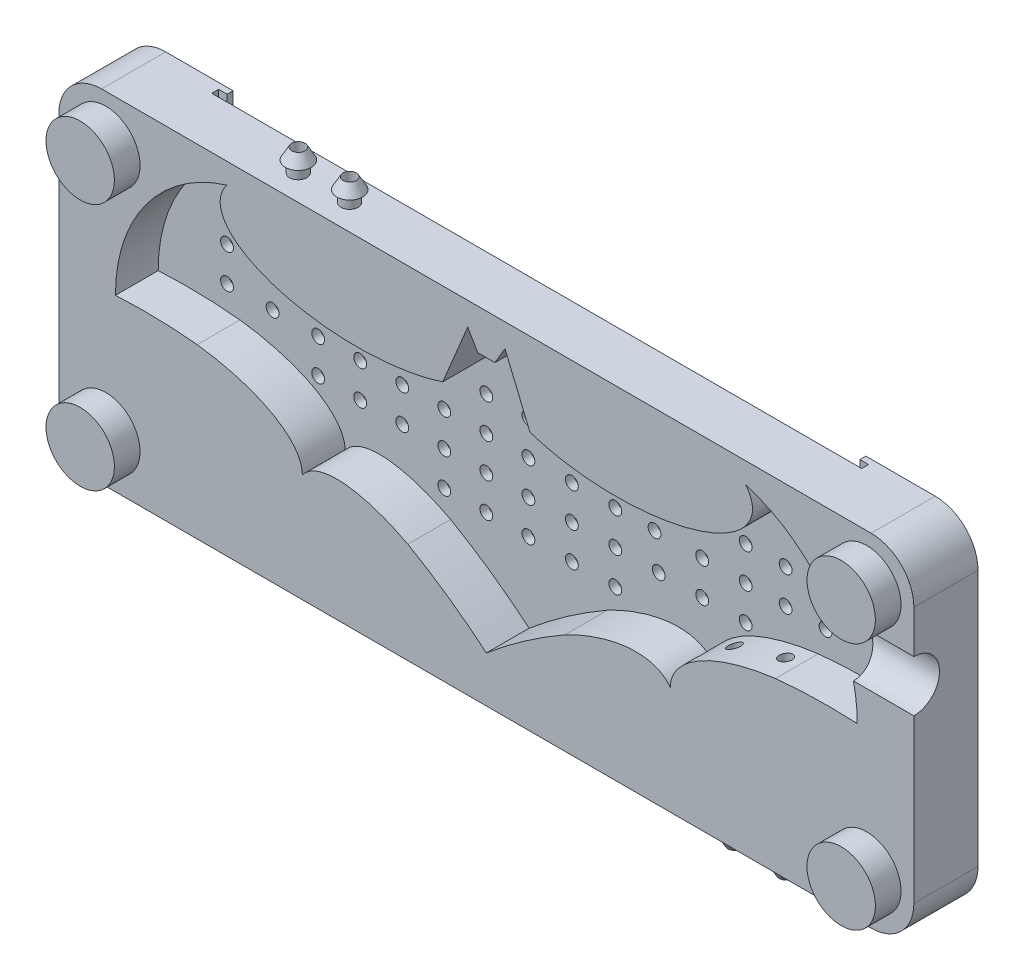
from build123d import *

# Parameters (mm, degrees)
CROQUIS2_W               = 50
CROQUIS2_H               = 40
SALIENTE_EXTRUIR1_DEPTH  = 7.5
CORTAR_EXTRUIR1_DEPTH    = 5
CROQUIS4_R               = 4
SALIENTE_EXTRUIR2_DEPTH  = 3
REDONDEO1_R              = 5
CORTAR_EXTRUIR3_DEPTH    = 10
CROQUIS9_R               = 0.75
CORTAR_EXTRUIR4_DEPTH    = 2.5
CORTAR_EXTRUIR5_DEPTH    = 30
CORTAR_EXTRUIR6_REACH    = 87.646
CROQUIS14_R              = 0.75
CORTAR_EXTRUIR7_REACH    = 87.646
CROQUIS15_R              = 0.75
CROQUIS16_R              = 1
CROQUIS16_R_2            = 0.75
SALIENTE_EXTRUIR6_DEPTH  = 1.3
MATRIZL1_COUNT           = 2
MATRIZL1_PITCH           = 6
CROQUIS27_R              = 1
CROQUIS27_R_2            = 0.75
SALIENTE_EXTRUIR11_DEPTH = 1.3
MATRIZL2_COUNT           = 2
MATRIZL2_PITCH           = 6


with BuildPart() as part:
    # Croquis2 → Saliente-Extruir1 (new body)
    with BuildSketch(Plane.XY):
        Rectangle(CROQUIS2_W, CROQUIS2_H)
    saliente_extruir1 = extrude(amount=SALIENTE_EXTRUIR1_DEPTH)

    # Croquis3 → Cortar-Extruir1 (cut)
    with BuildSketch(Plane.XY.offset(7.5)):
        with BuildLine():
            Line((19.901237938, 10.279897032), (22.822017531, 17.279897032))
            Line((22.822017531, 17.279897032), (24, 15.279897032))
            Line((24, 15.279897032), (25, 15.279897032))
            Line((25, 15.279897032), (25, -14.629122871))
            ThreePointArc((25, -14.629122871), (20.554365751, -11.20741121), (15.817639155, -8.201550981))
            add(Edge.make_bspline(
                [(15.817639155, -8.201550981), (6.428363836, -3.289480245), (3.480591711, -7.371484759)],
                knots=[5.017938201, 5.017938201, 5.017938201, 6.283185307, 6.283185307, 6.283185307], degree=2, weights=[1, 0.806479077, 1]))
            add(Edge.make_bspline(
                [(3.480591711, -7.371484759), (3.499026777, -1.865901054), (-8.816349071, -0.309137944)],
                knots=[3.141592654, 3.141592654, 3.141592654, 4.433520913, 4.433520913, 4.433520913], degree=2, weights=[1, 0.798519762, 1]))
            ThreePointArc((-8.816349071, -0.309137944), (-13.59205679, -0.015988385), (-18.376149655, -0.091990716))
            ThreePointArc((-18.376149655, -0.091990716), (-14.787337114, 10.909903735), (-5.334178799, 17.585160647))
            add(Edge.make_bspline(
                [(-5.334178799, 17.585160647), (-22.119144034, -3.87776365), (19.901237938, 10.279897032)],
                knots=[5.966710887, 5.966710887, 5.966710887, 8.531517406, 8.531517406, 8.531517406], degree=2, weights=[1, 0.284412024, 1]))
        make_face()
    cortar_extruir1 = extrude(amount=-CORTAR_EXTRUIR1_DEPTH, mode=Mode.SUBTRACT)

    # Simetría1: Saliente-Extruir1, Cortar-Extruir1 across plane
    add(saliente_extruir1.mirror(Plane(origin=(25, 20, 7.5), x_dir=(0, 0, 1), z_dir=(-1, 0, 0))))
    add(cortar_extruir1.mirror(Plane(origin=(25, 20, 7.5), x_dir=(0, 0, 1), z_dir=(-1, 0, 0))), mode=Mode.SUBTRACT)

    # Croquis4 → Saliente-Extruir2 (add)
    with BuildSketch(Plane.XY.offset(7.5)):
        with Locations((-19.5, 14.5)):
            Circle(CROQUIS4_R)
        with Locations((69.5, 14.5)):
            Circle(CROQUIS4_R)
        with Locations(Location((-19.5, -14.5, 0), (0, 0, 180))):
            Circle(CROQUIS4_R)
        with Locations(Location((69.5, -14.5, 0), (0, 0, 180))):
            Circle(CROQUIS4_R)
    extrude(amount=SALIENTE_EXTRUIR2_DEPTH)

    # Redondeo1
    redondeo1_edges = [part.edges().sort_by_distance(p)[0] for p in [
        (75, -20, 3.75),
        (75, 20, 3.75),
        (-25, -20, 3.75),
        (-25, 20, 3.75),
    ]]
    fillet(redondeo1_edges, radius=REDONDEO1_R)

    # Croquis8 → Cortar-Extruir3 (cut)
    with BuildSketch(Plane(origin=(75, 0, 0), x_dir=(0, 0, -1), z_dir=(1, 0, 0))):
        with BuildLine():
            Line((-7.5, 4), (-7.5, 10))
            ThreePointArc((-7.5, 10), (-4.5, 7), (-7.5, 4))
        make_face()
    extrude(amount=-CORTAR_EXTRUIR3_DEPTH, mode=Mode.SUBTRACT)

    # Croquis9 → Cortar-Extruir4 (cut)
    with BuildSketch(Plane(origin=(0, 0, 0), x_dir=(-1, 0, 0), z_dir=(0, 0, -1))):
        with Locations((-24.917645203, 2.6)):
            Circle(CROQUIS9_R)
        with Locations((-24.917645203, -1.4)):
            Circle(CROQUIS9_R)
        with Locations((-24.917645203, 6.6)):
            Circle(CROQUIS9_R)
        with Locations((-24.917645203, 10.6)):
            Circle(CROQUIS9_R)
        with Locations((-24.917645203, -5.4)):
            Circle(CROQUIS9_R)
        with Locations((-20, 2.6)):
            Circle(CROQUIS9_R)
        with Locations((-20, -1.4)):
            Circle(CROQUIS9_R)
        with Locations((-20, 6.6)):
            Circle(CROQUIS9_R)
        with Locations((-15.082354797, 2.6)):
            Circle(CROQUIS9_R)
        with Locations((-15.082354797, -1.4)):
            Circle(CROQUIS9_R)
        with Locations((-15.082354797, 6.6)):
            Circle(CROQUIS9_R)
        with Locations((-10.164709595, 2.6)):
            Circle(CROQUIS9_R)
        with Locations((-10.164709595, -1.4)):
            Circle(CROQUIS9_R)
        with Locations((-10.164709595, 6.6)):
            Circle(CROQUIS9_R)
        with Locations((-5.247064392, 2.6)):
            Circle(CROQUIS9_R)
        with Locations((-5.247064392, -1.4)):
            Circle(CROQUIS9_R)
        with Locations((-5.247064392, 6.6)):
            Circle(CROQUIS9_R)
        with Locations((-0.32941919, 2.6)):
            Circle(CROQUIS9_R)
        with Locations((-0.32941919, -1.4)):
            Circle(CROQUIS9_R)
        with Locations((-0.32941919, 6.6)):
            Circle(CROQUIS9_R)
        with Locations((-30, 2.6)):
            Circle(CROQUIS9_R)
        with Locations((-30, -1.4)):
            Circle(CROQUIS9_R)
        with Locations((-30, 6.6)):
            Circle(CROQUIS9_R)
        with Locations((-35.082354797, 2.6)):
            Circle(CROQUIS9_R)
        with Locations((-35.082354797, -1.4)):
            Circle(CROQUIS9_R)
        with Locations((-35.082354797, 6.6)):
            Circle(CROQUIS9_R)
        with Locations((-40.164709595, -1.4)):
            Circle(CROQUIS9_R)
        with Locations((-45.247064392, 2.6)):
            Circle(CROQUIS9_R)
        with Locations((-45.247064392, -1.4)):
            Circle(CROQUIS9_R)
        with Locations((-50.32941919, 2.6)):
            Circle(CROQUIS9_R)
        with Locations((-50.32941919, -1.4)):
            Circle(CROQUIS9_R)
        with Locations((-50.32941919, 6.6)):
            Circle(CROQUIS9_R)
        with Locations((-20, -5.4)):
            Circle(CROQUIS9_R)
        with Locations((-30, -5.4)):
            Circle(CROQUIS9_R)
        with Locations((-15.082354797, -5.4)):
            Circle(CROQUIS9_R)
        with Locations((-35.082354797, -5.4)):
            Circle(CROQUIS9_R)
        with Locations((-55, 6.6)):
            Circle(CROQUIS9_R)
        with Locations((-55, 2.6)):
            Circle(CROQUIS9_R)
        with Locations((-59.67058081, 6.6)):
            Circle(CROQUIS9_R)
        with Locations((-59.67058081, 2.6)):
            Circle(CROQUIS9_R)
        with Locations((-45, 6.6)):
            Circle(CROQUIS9_R)
        with Locations((5, 6.6)):
            Circle(CROQUIS9_R)
        with Locations((5, 2.6)):
            Circle(CROQUIS9_R)
        with Locations((-39.67058081, 6.6)):
            Circle(CROQUIS9_R)
        with Locations((-39.67058081, 2.6)):
            Circle(CROQUIS9_R)
        with Locations((10.32941919, 6.6)):
            Circle(CROQUIS9_R)
        with Locations((10.32941919, 2.6)):
            Circle(CROQUIS9_R)
        with Locations((10.32941919, 10.6)):
            Circle(CROQUIS9_R)
        with Locations((-59.67058081, 10.6)):
            Circle(CROQUIS9_R)
    extrude(amount=-CORTAR_EXTRUIR4_DEPTH, mode=Mode.SUBTRACT)

    # Croquis10 → Cortar-Extruir5 (cut)
    with BuildSketch(Plane(origin=(0, 20, 0), x_dir=(1, 0, 0), z_dir=(0, 1, 0))):
        Polygon((-12.114248309, 0), (-12.114248309, -0.7), (-13.114248309, -0.7), (-13.114248309, -1.5), (62.885751691, -1.5), (62.885751691, -0.7), (61.885751691, -0.7), (61.885751691, 0), align=None)
    extrude(amount=-CORTAR_EXTRUIR5_DEPTH, mode=Mode.SUBTRACT)

    # Croquis14 → Cortar-Extruir6 (cut, up to next)
    with BuildSketch(Plane(origin=(0, 20, 0), x_dir=(1, 0, 0), z_dir=(0, 1, 0)), mode=Mode.PRIVATE) as cortar_extruir6_sk1:
        with Locations(Location((0, -4.5, 0), (0, 0, 270))):
            Circle(CROQUIS14_R)
    cortar_extruir6_tool1 = extrude(cortar_extruir6_sk1.sketch, amount=-CORTAR_EXTRUIR6_REACH, mode=Mode.PRIVATE) & part.part
    # Croquis14 → Cortar-Extruir6 (cut, up to next)
    with BuildSketch(Plane(origin=(0, 20, 0), x_dir=(1, 0, 0), z_dir=(0, 1, 0)), mode=Mode.PRIVATE) as cortar_extruir6_sk2:
        with Locations(Location((6, -4.5, 0), (0, 0, 270))):
            Circle(CROQUIS14_R)
    cortar_extruir6_tool2 = extrude(cortar_extruir6_sk2.sketch, amount=-CORTAR_EXTRUIR6_REACH, mode=Mode.PRIVATE) & part.part
    add(cortar_extruir6_tool1.solids().sort_by_distance((0, 20, 4.5))[0], mode=Mode.SUBTRACT)
    add(cortar_extruir6_tool2.solids().sort_by_distance((6, 20, 4.5))[0], mode=Mode.SUBTRACT)

    # Croquis15 → Cortar-Extruir7 (cut, up to next)
    with BuildSketch(Plane.XZ.offset(20), mode=Mode.PRIVATE) as cortar_extruir7_sk1:
        with Locations(Location((57, 4.5, 0), (0, 0, 270))):
            Circle(CROQUIS15_R)
    cortar_extruir7_tool1 = extrude(cortar_extruir7_sk1.sketch, amount=-CORTAR_EXTRUIR7_REACH, mode=Mode.PRIVATE) & part.part
    # Croquis15 → Cortar-Extruir7 (cut, up to next)
    with BuildSketch(Plane.XZ.offset(20), mode=Mode.PRIVATE) as cortar_extruir7_sk2:
        with Locations(Location((51, 4.5, 0), (0, 0, 270))):
            Circle(CROQUIS15_R)
    cortar_extruir7_tool2 = extrude(cortar_extruir7_sk2.sketch, amount=-CORTAR_EXTRUIR7_REACH, mode=Mode.PRIVATE) & part.part
    add(cortar_extruir7_tool1.solids().sort_by_distance((57, -20, 4.5))[0], mode=Mode.SUBTRACT)
    add(cortar_extruir7_tool2.solids().sort_by_distance((51, -20, 4.5))[0], mode=Mode.SUBTRACT)

    # Croquis16 → Saliente-Extruir6 (add)
    with BuildSketch(Plane.XZ.offset(20)):
        with Locations(Location((51, 4.5, 0), (0, 0, 90))):
            Circle(CROQUIS16_R)
        with Locations(Location((51, 4.5, 0), (0, 0, 270))):
            Circle(CROQUIS16_R_2, mode=Mode.SUBTRACT)
        with Locations(Location((57, 4.5, 0), (0, 0, 90))):
            Circle(CROQUIS16_R)
        with Locations(Location((57, 4.5, 0), (0, 0, 270))):
            Circle(CROQUIS16_R_2, mode=Mode.SUBTRACT)
    extrude(amount=SALIENTE_EXTRUIR6_DEPTH)

    # Croquis26 → Revolución1 (revolve)
    with BuildSketch(Plane(origin=(51, 0, 0), x_dir=(0, 0, -1), z_dir=(1, 0, 0))):
        Polygon((-3.75, -21.3), (-3.75, -22.599038106), (-3, -21.3), (-3.5, -21.3), align=None)
    revoluci_n1 = revolve(axis=Axis((51, -21.3, 4.5), (0, -1, 0)))

    # MatrizL1: Revolución1 ×2
    with Locations(*[(i * MATRIZL1_PITCH, 0, 0) for i in range(1, MATRIZL1_COUNT)]):
        add(revoluci_n1)

    # Croquis27 → Saliente-Extruir11 (add)
    with BuildSketch(Plane(origin=(0, 20, 0), x_dir=(1, 0, 0), z_dir=(0, 1, 0))):
        with Locations(Location((0, -4.5, 0), (0, 0, 90))):
            Circle(CROQUIS27_R)
        with Locations(Location((0, -4.5, 0), (0, 0, 270))):
            Circle(CROQUIS27_R_2, mode=Mode.SUBTRACT)
        with Locations(Location((6, -4.5, 0), (0, 0, 90))):
            Circle(CROQUIS27_R)
        with Locations(Location((6, -4.5, 0), (0, 0, 270))):
            Circle(CROQUIS27_R_2, mode=Mode.SUBTRACT)
    extrude(amount=SALIENTE_EXTRUIR11_DEPTH)

    # Croquis29 → Revolución2 (revolve)
    with BuildSketch(Plane.ZY, mode=Mode.PRIVATE) as revoluci_n2_sk:
        Polygon((5.5, 21.3), (6, 21.3), (5.258620285, 22.603977039), (5.258620285, 21.3), align=None)
    revoluci_n2 = revolve(revoluci_n2_sk.sketch.rotate(Axis((0, 21.3, 4.484281898), (0, 1, 0)), 90), axis=Axis((0, 21.3, 4.484281898), (0, 1, 0)))

    # MatrizL2: Revolución2 ×2
    with Locations(*[(i * MATRIZL2_PITCH, 0, 0) for i in range(1, MATRIZL2_COUNT)]):
        add(revoluci_n2)


solid = part.part
